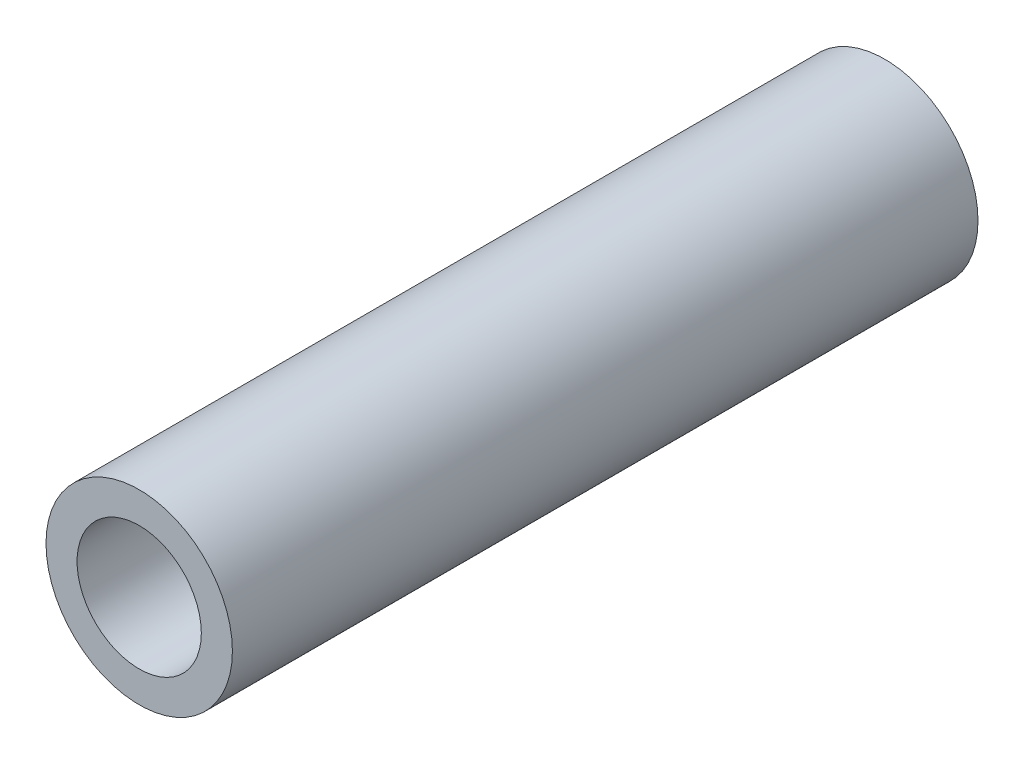
from build123d import *

# Parameters (mm, degrees)
SKETCH1_R           = 4.7625
SKETCH1_R_2         = 3.175
BOSS_EXTRUDE1_DEPTH = 38.1


with BuildPart() as part:
    # Sketch1 → Boss-Extrude1 (new body)
    with BuildSketch(Plane.XY):
        Circle(SKETCH1_R)
        Circle(SKETCH1_R_2, mode=Mode.SUBTRACT)
    extrude(amount=BOSS_EXTRUDE1_DEPTH)


solid = part.part
